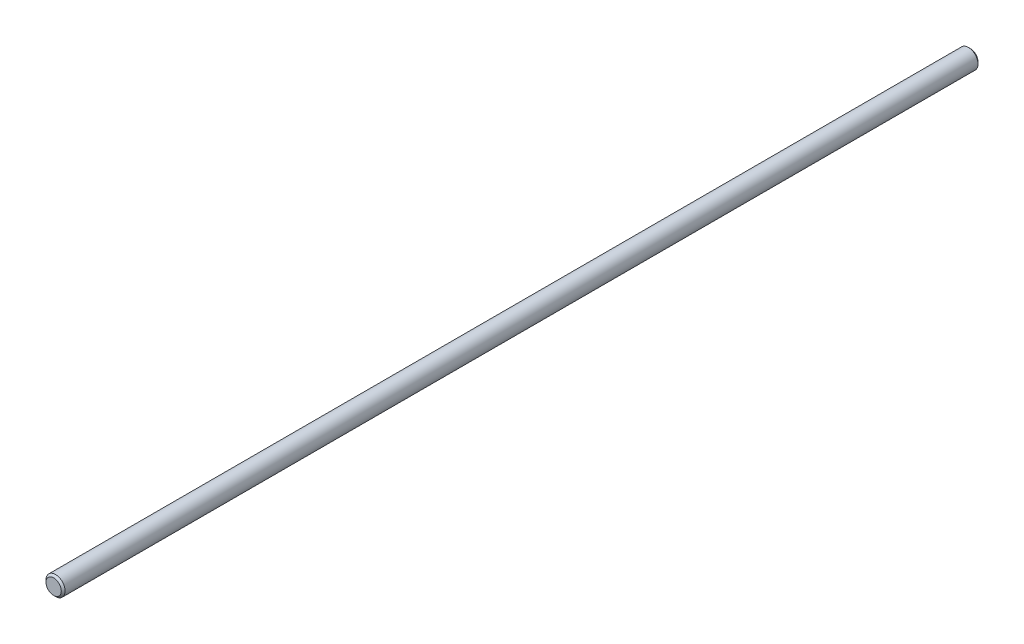
from build123d import *

# Parameters (mm, degrees)
SKETCH3_R           = 12.7
BOSS_EXTRUDE1_DEPTH = 609.6
CHAMFER1_SIZE       = 2.54


with BuildPart() as part:
    # Sketch3 → Boss-Extrude1 (new body, symmetric)
    with BuildSketch(Plane.XY):
        Circle(SKETCH3_R)
    extrude(amount=BOSS_EXTRUDE1_DEPTH, both=True)

    # Chamfer1
    chamfer1_edges = [part.edges().sort_by_distance(p)[0] for p in [
        (-12.7, 0, -609.6),
        (-12.7, 0, 609.6),
    ]]
    chamfer(chamfer1_edges, length=CHAMFER1_SIZE)


solid = part.part
